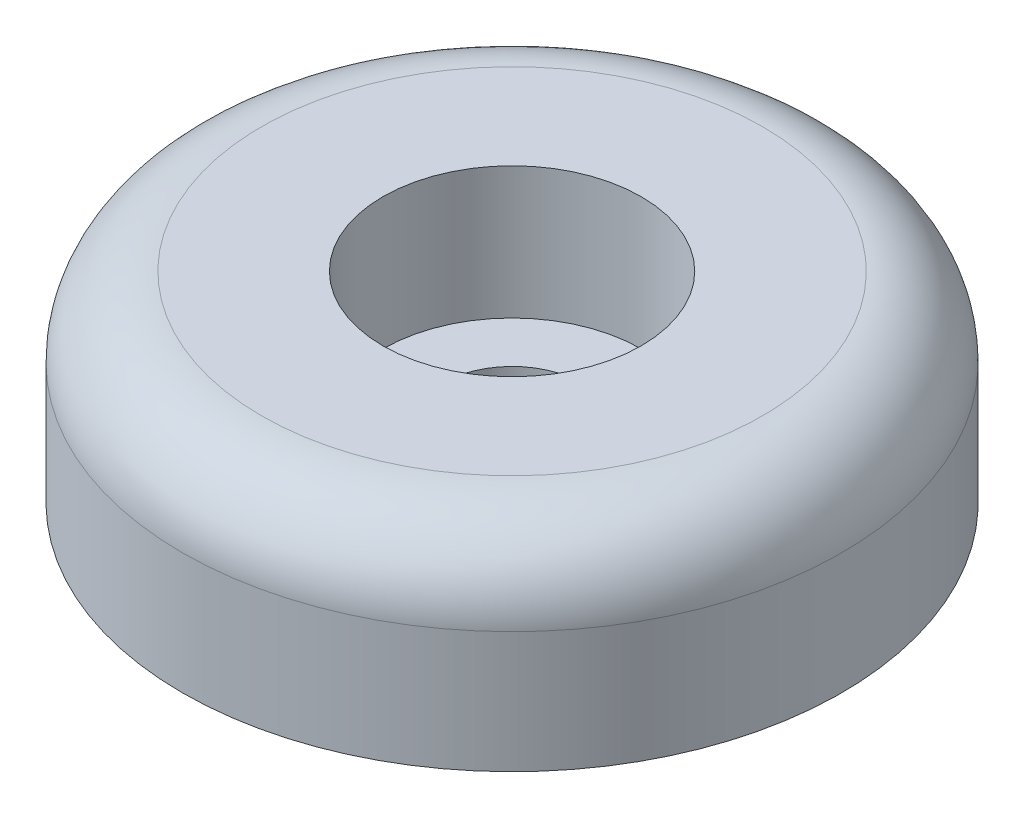
from build123d import *

# Parameters (mm, degrees)
CONG_1_R = 3


with BuildPart() as part:
    # Esquisse1 → Révolution1 (revolve)
    with BuildSketch(Plane.XY):
        Polygon((-2.65, 0), (-12.5, 0), (-12.5, 7.6), (-4.9, 7.6), (-4.9, 2.6), (-2.65, 2.6), align=None)
    revolve(axis=Axis((0, 17.675608337, 0), (0, -1, 0)))

    # Congé1
    cong_1_edges = [part.edges().sort_by_distance(p)[0] for p in [
        (12.5, 7.6, 0),
    ]]
    fillet(cong_1_edges, radius=CONG_1_R)


solid = part.part
